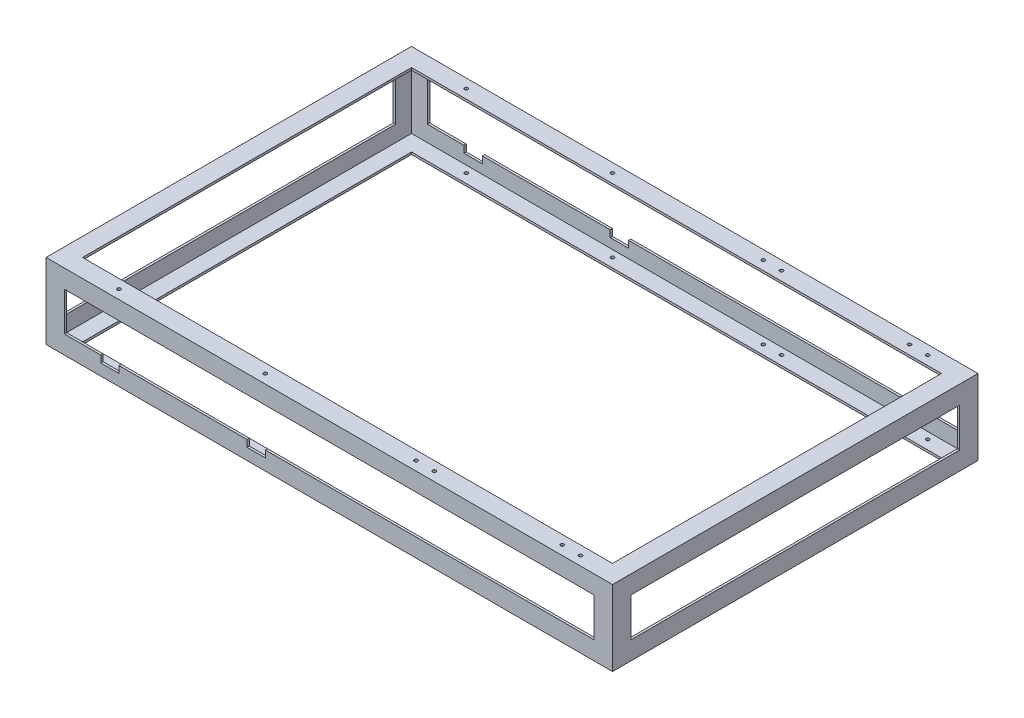
from build123d import *

# Parameters (mm, degrees)
X_ANGLE_LENTH_DEPTH             = 1574.8
X_ANGLE_LENTH_2_DEPTH           = 1574.8
X_ANGLE_LENTH_3_DEPTH           = 1574.8
X_ANGLE_LENTH_4_DEPTH           = 1574.8
Y_ANGLE_LENTH_DEPTH             = 209.55
Z_START                         = -457.2
Z_ANGLE_LENTH_DEPTH             = 914.4
SKETCH16_R                      = 4.7625
WHEEL_MOUNT_LOC_HOLES_DEPTH     = 210.55
SKETCH17_W                      = 50.8
SKETCH17_H                      = 38.1
FRONT_CONTROL_ARM_CUTOUTS_DEPTH = 1017
SKETCH19_R                      = 4
CUT_EXTRUDE1_DEPTH              = 7.35


with BuildPart() as part:
    # Sketch5 → X Angle Lenth (new body)
    with BuildSketch(Plane(origin=(0, 0, 0), x_dir=(0, 0, -1), z_dir=(1, 0, 0))):
        Polygon((-508, -304.8), (-508, -254), (-501.65, -254), (-501.65, -298.45), (-457.2, -298.45), (-457.2, -304.8), align=None)
    extrude(amount=X_ANGLE_LENTH_DEPTH)



with BuildPart() as body_2:
    # Sketch5 → X Angle Lenth 2 (new body)
    with BuildSketch(Plane(origin=(0, 0, 0), x_dir=(0, 0, -1), z_dir=(1, 0, 0))):
        Polygon((501.65, -254), (508, -254), (508, -304.8), (457.2, -304.8), (457.2, -298.45), (501.65, -298.45), align=None)
    extrude(amount=X_ANGLE_LENTH_2_DEPTH)


with BuildPart() as body_3:
    # Sketch5 → X Angle Lenth 3 (new body)
    with BuildSketch(Plane(origin=(0, 0, 0), x_dir=(0, 0, -1), z_dir=(1, 0, 0))):
        Polygon((508, -95.25), (508, -146.05), (501.65, -146.05), (501.65, -101.6), (457.2, -101.6), (457.2, -95.25), align=None)
    extrude(amount=X_ANGLE_LENTH_3_DEPTH)


with BuildPart() as body_4:
    # Sketch5 → X Angle Lenth 4 (new body)
    with BuildSketch(Plane(origin=(0, 0, 0), x_dir=(0, 0, -1), z_dir=(1, 0, 0))):
        Polygon((-501.65, -146.05), (-508, -146.05), (-508, -95.25), (-457.2, -95.25), (-457.2, -101.6), (-501.65, -101.6), align=None)
    extrude(amount=X_ANGLE_LENTH_4_DEPTH)


with BuildPart() as part_1:
    add(part.part)

    add(body_2.part)  # Y Angle Lenth merges body 2

    add(body_3.part)  # Y Angle Lenth merges body 3

    add(body_4.part)  # Y Angle Lenth merges body 4
    # Sketch6 → Y Angle Lenth (add)
    with BuildSketch(Plane.XZ.offset(304.8)):
        Polygon((1574.8, -508), (1524, -508), (1524, -501.65), (1568.45, -501.65), (1568.45, -457.2), (1574.8, -457.2), align=None)
        Polygon((1524, 501.65), (1524, 508), (1574.8, 508), (1574.8, 457.2), (1568.45, 457.2), (1568.45, 501.65), align=None)
        Polygon((0, 508), (50.8, 508), (50.8, 501.65), (6.35, 501.65), (6.35, 457.2), (0, 457.2), align=None)
        Polygon((50.8, -501.65), (50.8, -508), (0, -508), (0, -457.2), (6.35, -457.2), (6.35, -501.65), align=None)
    extrude(amount=-Y_ANGLE_LENTH_DEPTH)

    # Sketch15 → Z Angle Lenth (add)
    with BuildSketch(Plane.XY.offset(Z_START)):
        Polygon((0, -254), (0, -304.8), (50.8, -304.8), (50.8, -298.45), (6.35, -298.45), (6.35, -254), align=None)
        Polygon((1568.45, -254), (1574.8, -254), (1574.8, -304.8), (1524, -304.8), (1524, -298.45), (1568.45, -298.45), align=None)
        Polygon((1574.8, -146.05), (1574.8, -95.25), (1524, -95.25), (1524, -101.6), (1568.45, -101.6), (1568.45, -146.05), align=None)
        Polygon((6.35, -146.05), (0, -146.05), (0, -95.25), (50.8, -95.25), (50.8, -101.6), (6.35, -101.6), align=None)
    extrude(amount=Z_ANGLE_LENTH_DEPTH)

    # Sketch16 → Wheel Mount LOC Holes (cut, through all)
    with BuildSketch(Plane(origin=(0, -95.25, 0), x_dir=(1, 0, 0), z_dir=(0, 1, 0))):
        with Locations((1409.7, 482.6)):
            Circle(SKETCH16_R)
        with Locations((1003.3, 482.6)):
            Circle(SKETCH16_R)
        with Locations((584.2, 482.6)):
            Circle(SKETCH16_R)
        with Locations((177.8, 482.6)):
            Circle(SKETCH16_R)
        with Locations((177.8, -482.6)):
            Circle(SKETCH16_R)
        with Locations((584.2, -482.6)):
            Circle(SKETCH16_R)
        with Locations((1003.3, -482.6)):
            Circle(SKETCH16_R)
        with Locations((1409.7, -482.6)):
            Circle(SKETCH16_R)
        with Locations((1054.1, 482.6)):
            Circle(SKETCH16_R)
        with Locations((1460.5, 482.6)):
            Circle(SKETCH16_R)
        with Locations((1460.5, -482.6)):
            Circle(SKETCH16_R)
        with Locations((1054.1, -482.6)):
            Circle(SKETCH16_R)
    extrude(amount=-WHEEL_MOUNT_LOC_HOLES_DEPTH, mode=Mode.SUBTRACT)

    # Sketch17 → Front Control Arm Cutouts (cut, through all)
    with BuildSketch(Plane.XY.offset(508)):
        with Locations((177.8, -254)):
            Rectangle(SKETCH17_W, SKETCH17_H)
        with Locations((584.2, -254)):
            Rectangle(SKETCH17_W, SKETCH17_H)
    extrude(amount=-FRONT_CONTROL_ARM_CUTOUTS_DEPTH, mode=Mode.SUBTRACT)

    # Sketch19 → Cut-Extrude1 (cut, through all)
    with BuildSketch(Plane(origin=(0, -298.45, 0), x_dir=(1, 0, 0), z_dir=(0, 1, 0))):
        with Locations((736.6, -469.9)):
            Circle(SKETCH19_R)
        with Locations((772.6, -469.9)):
            Circle(SKETCH19_R)
    extrude(amount=-CUT_EXTRUDE1_DEPTH, mode=Mode.SUBTRACT)


solid = part_1.part
